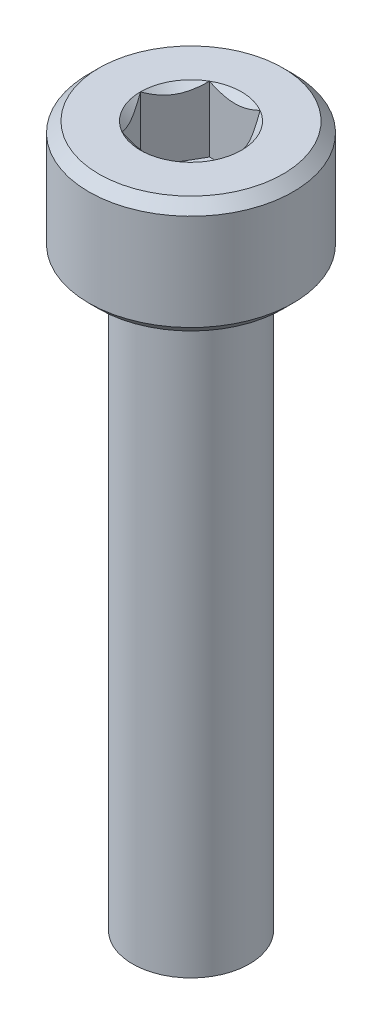
from build123d import *

# Parameters (mm, degrees)
SKETCH1_R           = 3.5
BOSS_EXTRUDE1_DEPTH = 4
CUT_EXTRUDE1_DEPTH  = 2.25
CHAMFER1_SIZE       = 0.35
SKETCH_1_R          = 2
EXTRUDE_1_DEPTH     = 20


with BuildPart() as part:
    # Sketch1 → Boss-Extrude1 (new body)
    with BuildSketch(Plane(origin=(0, 0, 0), x_dir=(1, 0, 0), z_dir=(0, 1, 0))):
        with Locations(Location((0, 0, 0), (0, 0, 270))):
            Circle(SKETCH1_R)
    extrude(amount=BOSS_EXTRUDE1_DEPTH)

    # Sketch2 → Cut-Extrude1 (cut)
    with BuildSketch(Plane(origin=(0, 4, 0), x_dir=(1, 0, 0), z_dir=(0, 1, 0))):
        Polygon((0.866025404, 1.5), (-0.866025404, 1.5), (-1.732050808, 0), (-0.866025404, -1.5), (0.866025404, -1.5), (1.732050808, 0), align=None)
    extrude(amount=-CUT_EXTRUDE1_DEPTH, mode=Mode.SUBTRACT)

    # Cut-Extrude2 cone 1 section (through the dimple's axis) → Cut-Extrude2 (revolve, cut)
    with BuildSketch(Plane(origin=(0, 4, 0), x_dir=(0, 0, 1), z_dir=(1, 0, 0))):
        Polygon((0, 0), (1.732050808, 0), (0, 1.732050808), align=None)
    revolve(axis=Axis((0, 4, 0), (0, -1, 0)), mode=Mode.SUBTRACT)

    # Chamfer1
    chamfer1_edges = [part.edges().sort_by_distance(p)[0] for p in [
        (0, 0, -3.5),
        (0, 4, -3.5),
    ]]
    chamfer(chamfer1_edges, length=CHAMFER1_SIZE)

    # 草图1 → 凸台-拉伸1 (add)
    with BuildSketch(Plane(origin=(0, 0, 0), x_dir=(-1, 0, 0), z_dir=(0, -1, 0))):
        with Locations(Location((0, 0, 0), (0, 0, 90))):
            Circle(SKETCH_1_R)
    extrude(amount=EXTRUDE_1_DEPTH)


solid = part.part
